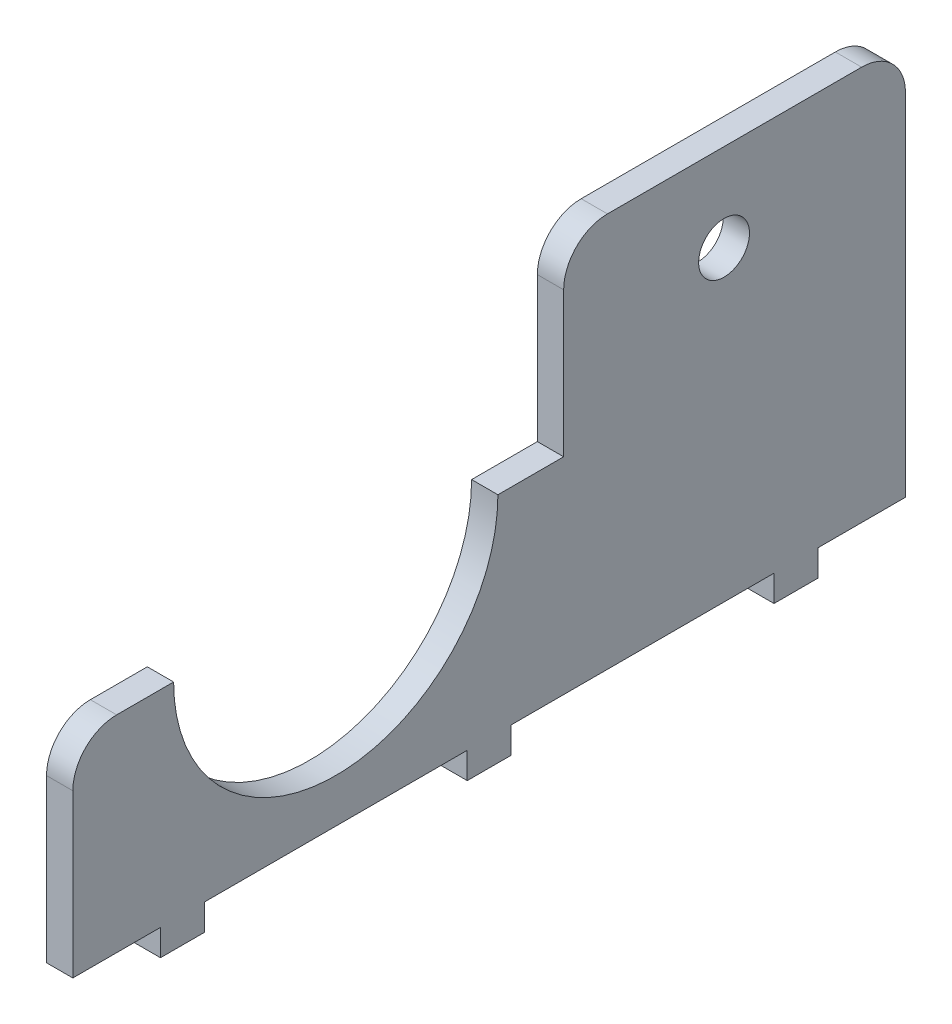
from build123d import *

# Parameters (mm, degrees)
BOSS_EXTRUDE1_DEPTH = 3
SKETCH3_W           = 3
SKETCH3_H           = 5
BOSS_EXTRUDE2_DEPTH = 3
SKETCH5_W           = 3
SKETCH5_H           = 39
BOSS_EXTRUDE3_DEPTH = 21.5
CUT_EXTRUDE3_DEPTH  = 4
FILLET1_R           = 5


with BuildPart() as part:
    # Sketch1 → Boss-Extrude1 (new body)
    with BuildSketch(Plane(origin=(0, 0, 0), x_dir=(0, 0, -1), z_dir=(1, 0, 0))):
        with BuildLine():
            Line((-36, 11.75), (-47.5, 11.75))
            Line((-47.5, 11.75), (-47.5, -11.75))
            Line((-47.5, -11.75), (47.5, -11.75))
            Line((47.5, -11.75), (47.5, 11.75))
            Line((47.5, 11.75), (1, 11.75))
            ThreePointArc((1, 11.75), (-17.5, -6.75), (-36, 11.75))
        make_face()
    extrude(amount=BOSS_EXTRUDE1_DEPTH)

    # Sketch3 → Boss-Extrude2 (add)
    with BuildSketch(Plane.XZ.offset(11.75)):
        with Locations((1.5, -35)):
            Rectangle(SKETCH3_W, SKETCH3_H)
        with Locations((1.5, 0)):
            Rectangle(SKETCH3_W, SKETCH3_H)
        with Locations((1.5, 35)):
            Rectangle(SKETCH3_W, SKETCH3_H)
    extrude(amount=BOSS_EXTRUDE2_DEPTH)

    # Sketch5 → Boss-Extrude3 (add)
    with BuildSketch(Plane(origin=(0, 11.75, 0), x_dir=(1, 0, 0), z_dir=(0, 1, 0))):
        with Locations((1.5, 28)):
            Rectangle(SKETCH5_W, SKETCH5_H)
    extrude(amount=BOSS_EXTRUDE3_DEPTH)

    # Sketch7 → Cut-Extrude3 (cut, through all)
    with BuildSketch(Plane.ZY):
        with BuildLine():
            ThreePointArc((-29.7, 23.25), (-26.8, 20.35), (-23.9, 23.25))
            ThreePointArc((-23.9, 23.25), (-26.8, 26.15), (-29.7, 23.25))
        make_face()
    extrude(amount=-CUT_EXTRUDE3_DEPTH, mode=Mode.SUBTRACT)

    # Fillet1
    fillet1_edges = [part.edges().sort_by_distance(p)[0] for p in [
        (1.5, 11.75, 47.5),
        (1.5, 33.25, -47.5),
        (1.5, 33.25, -8.5),
    ]]
    fillet(fillet1_edges, radius=FILLET1_R)


solid = part.part
